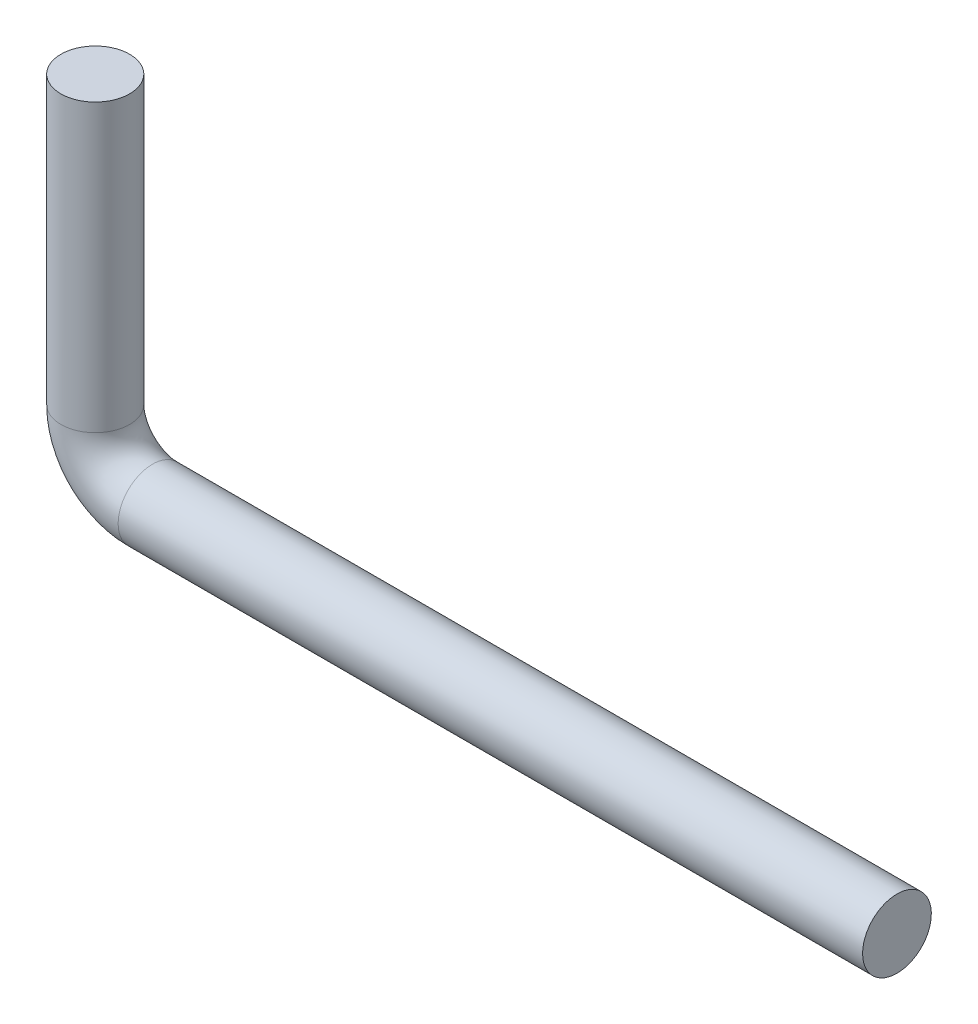
from build123d import *

# Parameters (mm, degrees)
SKETCH4_R = 6


with BuildPart() as part:
    # Sweep1: sweep along a path in Sketch3
    with BuildLine(Plane.XY) as sweep1_path:
        Line((0, 60), (0, 10))
        ThreePointArc((0, 10), (2.928932188, 2.928932188), (10, 0))
        Line((10, 0), (140, 0))
    # Sketch4 → Sweep1 (sweep)
    with BuildSketch(Plane(origin=(0, 60, 0), x_dir=(1, 0, 0), z_dir=(0, 1, 0))):
        Circle(SKETCH4_R)
    sweep(path=sweep1_path.line)


solid = part.part
